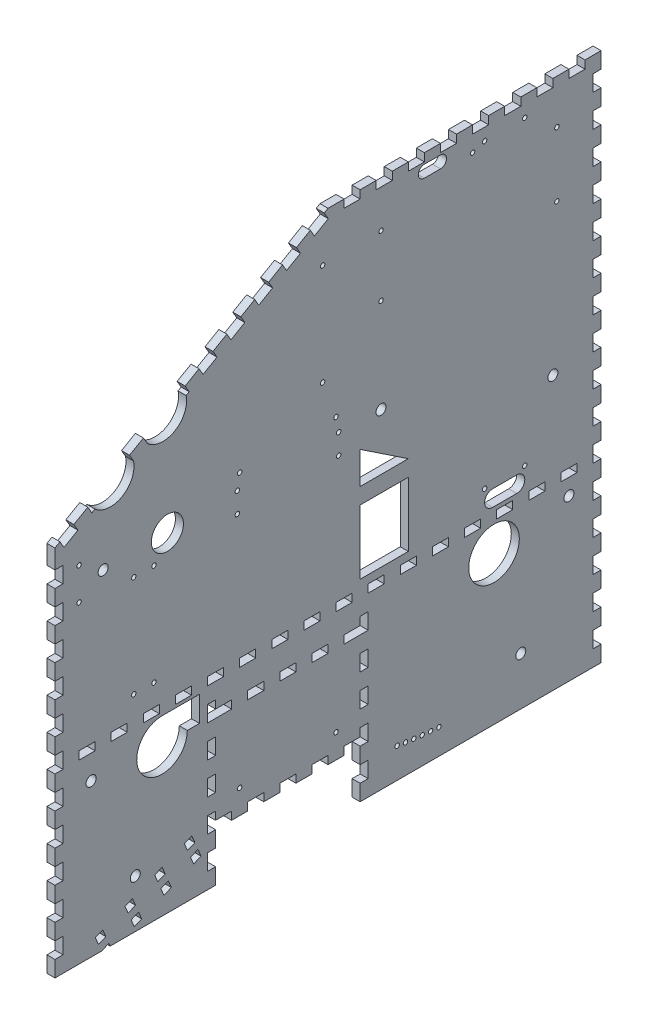
from build123d import *

# Parameters (mm, degrees)
BOSS_EXTRUDE1_DEPTH  = 6.35
SKETCH3_R            = 3.96875
CUT_EXTRUDE1_DEPTH   = 7.35
SKETCH4_R            = 1.75
CUT_EXTRUDE2_DEPTH   = 7.35
SKETCH5_W            = 6.35
SKETCH5_H            = 12.7
CUT_EXTRUDE3_DEPTH   = 7.35
LPATTERN1_COUNT      = 16
LPATTERN1_PITCH      = 25.4
SKETCH6_W            = 6.35
SKETCH6_H            = 12.7
CUT_EXTRUDE4_DEPTH   = 7.35
LPATTERN2_COUNT      = 11
LPATTERN2_PITCH      = 25.4
SKETCH7_W            = 6.35
SKETCH7_H            = 12.7
SKETCH7_W_2          = 12.7
SKETCH7_H_2          = 6.35
CUT_EXTRUDE5_DEPTH   = 7.35
CUT_EXTRUDE6_DEPTH   = 7.35
LPATTERN3_COUNT      = 10
LPATTERN3_PITCH      = 25.4
SKETCH9_W            = 12.7
SKETCH9_H            = 6.35
CUT_EXTRUDE7_DEPTH   = 7.35
LPATTERN4_COUNT      = 8
LPATTERN4_PITCH      = 25.4
SKETCH10_R           = 1.75
CUT_EXTRUDE8_DEPTH   = 7.35
SKETCH11_R           = 3.96875
CUT_EXTRUDE9_DEPTH   = 7.35
SKETCH12_W           = 6.35
SKETCH12_H           = 12.7
CUT_EXTRUDE13_DEPTH  = 7.35
SKETCH13_R           = 20
CUT_EXTRUDE14_DEPTH  = 7.35
CUT_EXTRUDE15_DEPTH  = 7.35
CUT_EXTRUDE16_DEPTH  = 7.35
SKETCH17_W           = 12.7
SKETCH17_H           = 6.35
CUT_EXTRUDE17_DEPTH  = 7.35
LPATTERN5_COUNT      = 17
LPATTERN5_PITCH      = 25.4
LPATTERN6_COUNT      = 2
LPATTERN6_PITCH      = 120.65
SKETCH18_W           = 12.7
SKETCH18_H           = 6.35
CUT_EXTRUDE18_DEPTH  = 7.35
LPATTERN7_COUNT      = 5
LPATTERN7_PITCH      = 25.4
SKETCH19_R           = 4
CUT_EXTRUDE19_DEPTH  = 7.35
CUT_EXTRUDE20_DEPTH  = 7.35
CUT_EXTRUDE22_DEPTH  = 7.35
LPATTERN9_COUNT      = 4
LPATTERN9_PITCH      = 25.4
LPATTERN10_COUNT     = 2
LPATTERN10_PITCH     = 12.7
LPATTERN10_COL_COUNT = 2
LPATTERN10_COL_PITCH = 12.7
SKETCH23_R           = 12.7
CUT_EXTRUDE23_DEPTH  = 7.35
CUT_EXTRUDE24_DEPTH  = 7.35
SKETCH26_W           = 38.1
SKETCH26_H           = 50.8
CUT_EXTRUDE26_DEPTH  = 7.35
CUT_EXTRUDE27_DEPTH  = 7.35
SKETCH28_W           = 17.264122815
SKETCH28_H           = 25.277581588
BOSS_EXTRUDE2_DEPTH  = 6.35
SKETCH29_W           = 29.65
SKETCH29_H           = 20
CUT_EXTRUDE28_DEPTH  = 7.35
SKETCH30_R           = 1.75
CUT_EXTRUDE29_DEPTH  = 7.35
SKETCH31_R           = 1.75
CUT_EXTRUDE30_DEPTH  = 7.35
SKETCH32_R           = 1.75
CUT_EXTRUDE31_DEPTH  = 7.35
SKETCH33_R           = 1.75
CUT_EXTRUDE32_DEPTH  = 7.35
SKETCH34_R           = 3.96875
CUT_EXTRUDE33_DEPTH  = 7.35
SKETCH35_R           = 3.96875
CUT_EXTRUDE34_DEPTH  = 7.35


with BuildPart() as part:
    # Sketch2 → Boss-Extrude1 (new body)
    with BuildSketch(Plane(origin=(0, 0, 0), x_dir=(0, 0, -1), z_dir=(1, 0, 0))):
        Polygon((0, 0), (0, 294.450076882), (215.9, 419.1), (431.8, 419.1), (431.8, 0), (241.3, 0), (241.3, 38.1), (127, 38.1), (127, 0), align=None)
    extrude(amount=BOSS_EXTRUDE1_DEPTH)

    # Sketch3 → Cut-Extrude1 (cut, through all)
    with BuildSketch(Plane(origin=(6.35, 0, 0), x_dir=(0, 0, -1), z_dir=(1, 0, 0))):
        with Locations((63.5, 38.1)):
            Circle(SKETCH3_R)
        with Locations((368.3, 38.1)):
            Circle(SKETCH3_R)
    extrude(amount=-CUT_EXTRUDE1_DEPTH, mode=Mode.SUBTRACT)

    # Sketch4 → Cut-Extrude2 (cut, through all)
    with BuildSketch(Plane(origin=(6.35, 0, 0), x_dir=(0, 0, -1), z_dir=(1, 0, 0))):
        with Locations((330.2, 400.05)):
            Circle(SKETCH4_R)
        with Locations((303.622783503, 19.978096851)):
            Circle(SKETCH4_R)
        with Locations((296.993662013, 20.499820027)):
            Circle(SKETCH4_R)
        with Locations((290.374655495, 21.137157865)):
            Circle(SKETCH4_R)
        with Locations((283.767780163, 21.889916225)):
            Circle(SKETCH4_R)
        with Locations((277.175048534, 22.757865809)):
            Circle(SKETCH4_R)
        with Locations((270.59846882, 23.740742233)):
            Circle(SKETCH4_R)
    extrude(amount=-CUT_EXTRUDE2_DEPTH, mode=Mode.SUBTRACT)

    # Sketch5 → Cut-Extrude3 (cut, through all)
    with BuildSketch(Plane(origin=(6.35, 0, 0), x_dir=(0, 0, -1), z_dir=(1, 0, 0))):
        with Locations((428.625, 19.05)):
            Rectangle(SKETCH5_W, SKETCH5_H)
    cut_extrude3 = extrude(amount=-CUT_EXTRUDE3_DEPTH, mode=Mode.SUBTRACT)

    # LPattern1: Cut-Extrude3 ×16
    with Locations(*[(0, i * LPATTERN1_PITCH, 0) for i in range(1, LPATTERN1_COUNT)]):
        add(cut_extrude3, mode=Mode.SUBTRACT)

    # Sketch6 → Cut-Extrude4 (cut, through all)
    with BuildSketch(Plane(origin=(6.35, 0, 0), x_dir=(0, 0, -1), z_dir=(1, 0, 0))):
        with Locations((3.175, 19.05)):
            Rectangle(SKETCH6_W, SKETCH6_H)
    cut_extrude4 = extrude(amount=-CUT_EXTRUDE4_DEPTH, mode=Mode.SUBTRACT)

    # LPattern2: Cut-Extrude4 ×11
    with Locations(*[(0, i * LPATTERN2_PITCH, 0) for i in range(1, LPATTERN2_COUNT)]):
        add(cut_extrude4, mode=Mode.SUBTRACT)

    # Sketch7 → Cut-Extrude5 (cut, through all)
    with BuildSketch(Plane(origin=(6.35, 0, 0), x_dir=(0, 0, -1), z_dir=(1, 0, 0))):
        with Locations((123.825, 19.05)):
            Rectangle(SKETCH7_W, SKETCH7_H)
        with Locations((133.35, 41.275)):
            Rectangle(SKETCH7_W_2, SKETCH7_H_2)
        with Locations((158.75, 41.275)):
            Rectangle(SKETCH7_W_2, SKETCH7_H_2)
        with Locations((184.15, 41.275)):
            Rectangle(SKETCH7_W_2, SKETCH7_H_2)
        with Locations((244.475, 19.05)):
            Rectangle(SKETCH7_W, SKETCH7_H)
        with Locations((209.55, 41.275)):
            Rectangle(SKETCH7_W_2, SKETCH7_H_2)
        with Locations((234.95, 41.275)):
            Rectangle(SKETCH7_W_2, SKETCH7_H_2)
    extrude(amount=-CUT_EXTRUDE5_DEPTH, mode=Mode.SUBTRACT)

    # Sketch8 → Cut-Extrude6 (cut, through all)
    with BuildSketch(Plane(origin=(6.35, 0, 0), x_dir=(0, 0, -1), z_dir=(1, 0, 0))):
        Polygon((201.93507044, 411.037344159), (212.933593068, 417.387344159), (216.108593068, 411.888082845), (205.11007044, 405.538082845), align=None)
    cut_extrude6 = extrude(amount=-CUT_EXTRUDE6_DEPTH, mode=Mode.SUBTRACT)

    # LPattern3: Cut-Extrude6 ×10
    with Locations(*[Vector(0, -0.5, 0.866025404) * (i * LPATTERN3_PITCH) for i in range(1, LPATTERN3_COUNT)]):
        add(cut_extrude6, mode=Mode.SUBTRACT)

    # Sketch9 → Cut-Extrude7 (cut, through all)
    with BuildSketch(Plane(origin=(6.35, 0, 0), x_dir=(0, 0, -1), z_dir=(1, 0, 0))):
        with Locations((412.75, 415.925)):
            Rectangle(SKETCH9_W, SKETCH9_H)
    cut_extrude7 = extrude(amount=-CUT_EXTRUDE7_DEPTH, mode=Mode.SUBTRACT)

    # LPattern4: Cut-Extrude7 ×8
    with Locations(*[(0, 0, i * LPATTERN4_PITCH) for i in range(1, LPATTERN4_COUNT)]):
        add(cut_extrude7, mode=Mode.SUBTRACT)

    # Sketch10 → Cut-Extrude8 (cut, through all)
    with BuildSketch(Plane(origin=(6.35, 0, 0), x_dir=(0, 0, -1), z_dir=(1, 0, 0))):
        with Locations((222.25, 273.05)):
            Circle(SKETCH10_R)
        with Locations((222.25, 57.15)):
            Circle(SKETCH10_R)
        with Locations((146.05, 57.15)):
            Circle(SKETCH10_R)
        with Locations((146.05, 273.05)):
            Circle(SKETCH10_R)
        with Locations((19.05, 273.05)):
            Circle(SKETCH10_R)
        with Locations((19.05, 247.65)):
            Circle(SKETCH10_R)
    extrude(amount=-CUT_EXTRUDE8_DEPTH, mode=Mode.SUBTRACT)

    # Sketch11 → Cut-Extrude9 (cut, through all)
    with BuildSketch(Plane(origin=(6.35, 0, 0), x_dir=(0, 0, -1), z_dir=(1, 0, 0))):
        with Locations((38.1, 260.35)):
            Circle(SKETCH11_R)
        with Locations((257.81, 260.35)):
            Circle(SKETCH11_R)
    extrude(amount=-CUT_EXTRUDE9_DEPTH, mode=Mode.SUBTRACT)

    # Sketch12 → Cut-Extrude13 (cut, through all)
    with BuildSketch(Plane(origin=(6.35, 0, 0), x_dir=(0, 0, -1), z_dir=(1, 0, 0))):
        with Locations((123.825, 44.45)):
            Rectangle(SKETCH12_W, SKETCH12_H)
        with Locations((123.825, 69.85)):
            Rectangle(SKETCH12_W, SKETCH12_H)
        with Locations((123.825, 95.25)):
            Rectangle(SKETCH12_W, SKETCH12_H)
        with Locations((123.825, 120.65)):
            Rectangle(SKETCH12_W, SKETCH12_H)
    cut_extrude13 = extrude(amount=-CUT_EXTRUDE13_DEPTH, mode=Mode.SUBTRACT)

    # Sketch13 → Cut-Extrude14 (cut, through all)
    with BuildSketch(Plane(origin=(6.35, 0, 0), x_dir=(0, 0, -1), z_dir=(1, 0, 0))):
        with Locations((84.65, 117.2)):
            Circle(SKETCH13_R)
        with Locations((347.15, 117.2)):
            Circle(SKETCH13_R)
    extrude(amount=-CUT_EXTRUDE14_DEPTH, mode=Mode.SUBTRACT)

    # Sketch14 → Cut-Extrude15 (cut, through all)
    with BuildSketch(Plane(origin=(6.35, 0, 0), x_dir=(0, 0, -1), z_dir=(1, 0, 0))):
        Polygon((36.957231019, 315.787344159), (47.955753647, 322.137344159), (51.130753647, 316.638082845), (40.132231019, 310.288082845), align=None)
        Polygon((80.951321531, 341.187344159), (91.949844159, 347.537344159), (95.124844159, 342.038082845), (84.126321531, 335.688082845), align=None)
    extrude(amount=-CUT_EXTRUDE15_DEPTH, mode=Mode.SUBTRACT)

    # Sketch15 → Cut-Extrude16 (cut, through all)
    with BuildSketch(Plane(origin=(6.35, 0, 0), x_dir=(0, 0, -1), z_dir=(1, 0, 0))):
        with BuildLine():
            Line((62.129276275, 322.988082845), (31.558579521, 305.338082845))
            ThreePointArc((31.558579521, 305.338082845), (51.535904978, 302.314952438), (62.501260575, 319.285333297))
            ThreePointArc((62.501260575, 319.285333297), (62.408031035, 321.146027155), (62.129276275, 322.988082845))
        make_face()
        with BuildLine():
            Line((103.698495657, 346.988082845), (73.127798903, 329.338082845))
            ThreePointArc((73.127798903, 329.338082845), (93.10512436, 326.314952438), (104.070479957, 343.285333297))
            ThreePointArc((104.070479957, 343.285333297), (103.977250417, 345.146027155), (103.698495657, 346.988082845))
        make_face()
    extrude(amount=-CUT_EXTRUDE16_DEPTH, mode=Mode.SUBTRACT)

    # Sketch17 → Cut-Extrude17 (cut, through all)
    with BuildSketch(Plane(origin=(6.35, 0, 0), x_dir=(0, 0, -1), z_dir=(1, 0, 0))):
        with Locations((25.4, 142.875)):
            Rectangle(SKETCH17_W, SKETCH17_H)
    cut_extrude17 = extrude(amount=-CUT_EXTRUDE17_DEPTH, mode=Mode.SUBTRACT)

    # LPattern5: Cut-Extrude17 ×17
    with Locations(*[(0, 0, -i * LPATTERN5_PITCH) for i in range(1, LPATTERN5_COUNT)]):
        add(cut_extrude17, mode=Mode.SUBTRACT)

    # LPattern6: Cut-Extrude13 ×2
    with Locations(*[(0, 0, -i * LPATTERN6_PITCH) for i in range(1, LPATTERN6_COUNT)]):
        add(cut_extrude13, mode=Mode.SUBTRACT)

    # Sketch18 → Cut-Extrude18 (cut, through all)
    with BuildSketch(Plane(origin=(6.35, 0, 0), x_dir=(0, 0, -1), z_dir=(1, 0, 0))):
        with Locations((133.35, 117.475)):
            Rectangle(SKETCH18_W, SKETCH18_H)
    cut_extrude18 = extrude(amount=-CUT_EXTRUDE18_DEPTH, mode=Mode.SUBTRACT)

    # LPattern7: Cut-Extrude18 ×5
    with Locations(*[(0, 0, -i * LPATTERN7_PITCH) for i in range(1, LPATTERN7_COUNT)]):
        add(cut_extrude18, mode=Mode.SUBTRACT)

    # Sketch19 → Cut-Extrude19 (cut, through all)
    with BuildSketch(Plane(origin=(6.35, 0, 0), x_dir=(0, 0, -1), z_dir=(1, 0, 0))):
        with Locations((28.575, 107.95)):
            Circle(SKETCH19_R)
    cut_extrude19 = extrude(amount=-CUT_EXTRUDE19_DEPTH, mode=Mode.SUBTRACT)

    # Sketch20 → Cut-Extrude20 (cut, through all)
    with BuildSketch(Plane(origin=(6.35, 0, 0), x_dir=(0, 0, -1), z_dir=(1, 0, 0))):
        with BuildLine():
            Line((292.1, 411.1625), (304.8, 411.1625))
            ThreePointArc((304.8, 411.1625), (309.5625, 406.4), (304.8, 401.6375))
            Line((304.8, 401.6375), (292.1, 401.6375))
            ThreePointArc((292.1, 401.6375), (287.3375, 406.4), (292.1, 411.1625))
        make_face()
    extrude(amount=-CUT_EXTRUDE20_DEPTH, mode=Mode.SUBTRACT)

    # Sketch22 → Cut-Extrude22 (cut, through all)
    with BuildSketch(Plane(origin=(6.35, 0, 0), x_dir=(0, 0, -1), z_dir=(1, 0, 0))):
        Polygon((104.768392524, 34.958218027), (102.338352728, 40.824853058), (108.20498776, 43.254892854), (110.635027555, 37.388257822), align=None)
        Polygon((107.198432319, 29.091582995), (109.628472115, 23.224947964), (115.495107146, 25.65498776), (113.065067351, 31.521622791), align=None)
    cut_extrude22 = extrude(amount=-CUT_EXTRUDE22_DEPTH, mode=Mode.SUBTRACT)

    # LPattern9: Cut-Extrude22 ×4
    with Locations(*[Vector(0, -0.382683432, 0.923879533) * (i * LPATTERN9_PITCH) for i in range(1, LPATTERN9_COUNT)]):
        add(cut_extrude22, mode=Mode.SUBTRACT)

    # LPattern10: Cut-Extrude19 ×2
    with Locations(*[(0, -i * LPATTERN10_PITCH, 0) for i in range(1, LPATTERN10_COUNT)]):
        add(cut_extrude19, mode=Mode.SUBTRACT)

    # LPattern10 col: Cut-Extrude19 ×2
    with Locations(*[(0, i * LPATTERN10_COL_PITCH, 0) for i in range(1, LPATTERN10_COL_COUNT)]):
        add(cut_extrude19, mode=Mode.SUBTRACT)

    # Sketch23 → Cut-Extrude23 (cut, through all)
    with BuildSketch(Plane(origin=(6.35, 0, 0), x_dir=(0, 0, -1), z_dir=(1, 0, 0))):
        with Locations((88.9, 260.35)):
            Circle(SKETCH23_R)
    extrude(amount=-CUT_EXTRUDE23_DEPTH, mode=Mode.SUBTRACT)

    # Sketch24 → Cut-Extrude24 (cut, through all)
    with BuildSketch(Plane(origin=(6.35, 0, 0), x_dir=(0, 0, -1), z_dir=(1, 0, 0))):
        with BuildLine():
            Line((365.125, 149.225), (346.075, 149.225))
            ThreePointArc((346.075, 149.225), (339.725, 155.575), (346.075, 161.925))
            Line((346.075, 161.925), (365.125, 161.925))
            ThreePointArc((365.125, 161.925), (371.475, 155.575), (365.125, 149.225))
        make_face()
    extrude(amount=-CUT_EXTRUDE24_DEPTH, mode=Mode.SUBTRACT)

    # Sketch26 → Cut-Extrude26 (cut, through all)
    with BuildSketch(Plane(origin=(6.35, 0, 0), x_dir=(0, 0, -1), z_dir=(1, 0, 0))):
        with Locations((260.35, 177.8)):
            Rectangle(SKETCH26_W, SKETCH26_H)
    extrude(amount=-CUT_EXTRUDE26_DEPTH, mode=Mode.SUBTRACT)

    # Sketch27 → Cut-Extrude27 (cut, through all)
    with BuildSketch(Plane(origin=(6.35, 0, 0), x_dir=(0, 0, -1), z_dir=(1, 0, 0))):
        Polygon((241.3, 215.9), (241.3, 241.3), (279.4, 215.9), align=None)
    extrude(amount=-CUT_EXTRUDE27_DEPTH, mode=Mode.SUBTRACT)

    # Sketch28 → Boss-Extrude2 (add, through all)
    with BuildSketch(Plane(origin=(6.35, 0, 0), x_dir=(0, 0, -1), z_dir=(1, 0, 0))):
        with Locations((27.283801439, 100.692653681)):
            Rectangle(SKETCH28_W, SKETCH28_H)
    extrude(amount=-BOSS_EXTRUDE2_DEPTH)

    # Sketch29 → Cut-Extrude28 (cut, through all)
    with BuildSketch(Plane(origin=(6.35, 0, 0), x_dir=(0, 0, -1), z_dir=(1, 0, 0))):
        with Locations((99.475, 127.2)):
            Rectangle(SKETCH29_W, SKETCH29_H)
    extrude(amount=-CUT_EXTRUDE28_DEPTH, mode=Mode.SUBTRACT)

    # Sketch30 → Cut-Extrude29 (cut, through all)
    with BuildSketch(Plane.ZY):
        with Locations((-371.475, 165.1)):
            Circle(SKETCH30_R)
        with Locations((-339.725, 165.1)):
            Circle(SKETCH30_R)
        with Locations((-339.725, 403.225)):
            Circle(SKETCH30_R)
        with Locations((-371.475, 403.225)):
            Circle(SKETCH30_R)
    extrude(amount=-CUT_EXTRUDE29_DEPTH, mode=Mode.SUBTRACT)

    # Sketch31 → Cut-Extrude30 (cut, through all)
    with BuildSketch(Plane.ZY):
        with Locations((-78.3, 243.25)):
            Circle(SKETCH31_R)
        with Locations((-62.3, 243.25)):
            Circle(SKETCH31_R)
        with Locations((-62.3, 163.11135182)):
            Circle(SKETCH31_R)
        with Locations((-78.3, 163.11135182)):
            Circle(SKETCH31_R)
    extrude(amount=-CUT_EXTRUDE30_DEPTH, mode=Mode.SUBTRACT)

    # Sketch32 → Cut-Extrude31 (cut, through all)
    with BuildSketch(Plane.ZY):
        with Locations((-211.65, 382.05)):
            Circle(SKETCH32_R)
        with Locations((-211.65, 301.91135182)):
            Circle(SKETCH32_R)
        with Locations((-224.33864818, 261.55)):
            Circle(SKETCH32_R)
        with Locations((-224.33864818, 245.55)):
            Circle(SKETCH32_R)
        with Locations((-144.2, 261.55)):
            Circle(SKETCH32_R)
        with Locations((-144.2, 245.55)):
            Circle(SKETCH32_R)
    extrude(amount=-CUT_EXTRUDE31_DEPTH, mode=Mode.SUBTRACT)

    # Sketch33 → Cut-Extrude32 (cut, through all)
    with BuildSketch(Plane.ZY):
        with Locations((-396.875, 384.175)):
            Circle(SKETCH33_R)
        with Locations((-396.875, 333.375)):
            Circle(SKETCH33_R)
        with Locations((-257.825, 334.775)):
            Circle(SKETCH33_R)
        with Locations((-257.825, 382.775)):
            Circle(SKETCH33_R)
    extrude(amount=-CUT_EXTRUDE32_DEPTH, mode=Mode.SUBTRACT)

    # Sketch34 → Cut-Extrude33 (cut, through all)
    with BuildSketch(Plane.ZY):
        with Locations((-406.4, 127)):
            Circle(SKETCH34_R)
    extrude(amount=-CUT_EXTRUDE33_DEPTH, mode=Mode.SUBTRACT)

    # Sketch35 → Cut-Extrude34 (cut, through all)
    with BuildSketch(Plane.ZY):
        with Locations((-393.7, 215.9)):
            Circle(SKETCH35_R)
    extrude(amount=-CUT_EXTRUDE34_DEPTH, mode=Mode.SUBTRACT)


solid = part.part
